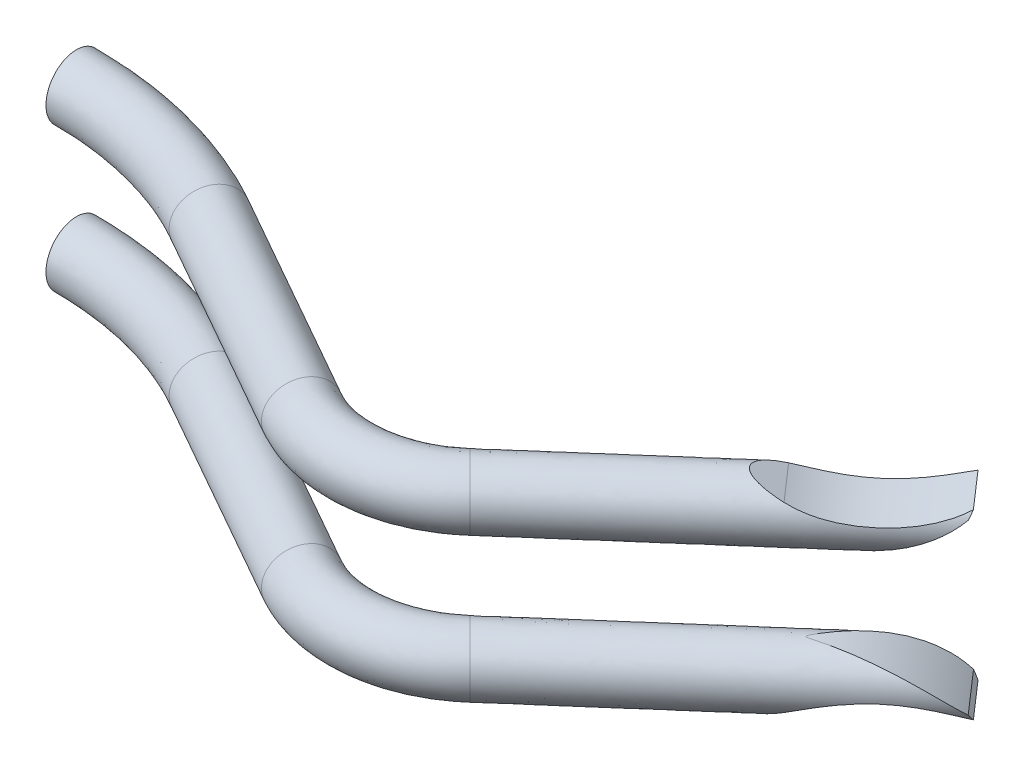
from build123d import *

# Parameters (mm, degrees)
SKETCH2_R          = 0.425
CUT_EXTRUDE2_DEPTH = 10


with BuildPart() as part:
    # Sweep4: sweep along a path in Sketch4
    with BuildLine(Plane(origin=(0, 0, 0), x_dir=(1, 0, 0), z_dir=(0, 1, 0))) as sweep4_path:
        Line((67.536722789, 33.517901337), (63.696993057, 30.160880485))
        ThreePointArc((63.696993057, 30.160880485), (62.67844941, 29.718218887), (61.591563938, 29.94638641))
        Line((61.591563938, 29.94638641), (58.647554869, 31.613971966))
        ThreePointArc((58.647554869, 31.613971966), (57.417647247, 32.11454889), (56.100779486, 32.285163408))
    # Sketch2 → Sweep4 (sweep)
    with BuildSketch(Plane(origin=(50.527312063, 4.259e-06, -50.527312063), x_dir=(0.707106781, 0, 0.707106781), z_dir=(0.707106781, 6e-08, -0.707106781))):
        with Locations((24.054939337, 4.259e-06)):
            Circle(SKETCH2_R)
    sweep(path=sweep4_path.line)

    # Sketch7 → Cut-Extrude2 (cut)
    with BuildSketch(Plane(origin=(12.979011819, 0, 14.845274956), x_dir=(-0.752843126, 0, 0.65819999), z_dir=(-0.65819999, 0, -0.752843126))):
        with BuildLine():
            Line((-70.90689286, -0.258658753), (-70.424884302, -0.480296071))
            Line((-70.424884302, -0.480296071), (-73.177134487, -0.809094289))
            Line((-73.177134487, -0.809094289), (-73.643040117, 0.425))
            Line((-73.643040117, 0.425), (-71.097248445, 0.425))
            ThreePointArc((-71.097248445, 0.425), (-71.956470511, 0.264804948), (-72.71646768, -0.166853846))
            Line((-72.71646768, -0.166853846), (-72.763912994, -0.258658753))
            ThreePointArc((-72.763912994, -0.258658753), (-71.835402927, -0.055413386), (-70.90689286, -0.258658753))
        make_face()
    extrude(amount=CUT_EXTRUDE2_DEPTH, mode=Mode.SUBTRACT)


with BuildPart() as body_2:
    # Mirror1: mirrored copy
    add(part.part.mirror(Plane.ZX.offset(1)))


solid = Compound([part.part, body_2.part])
